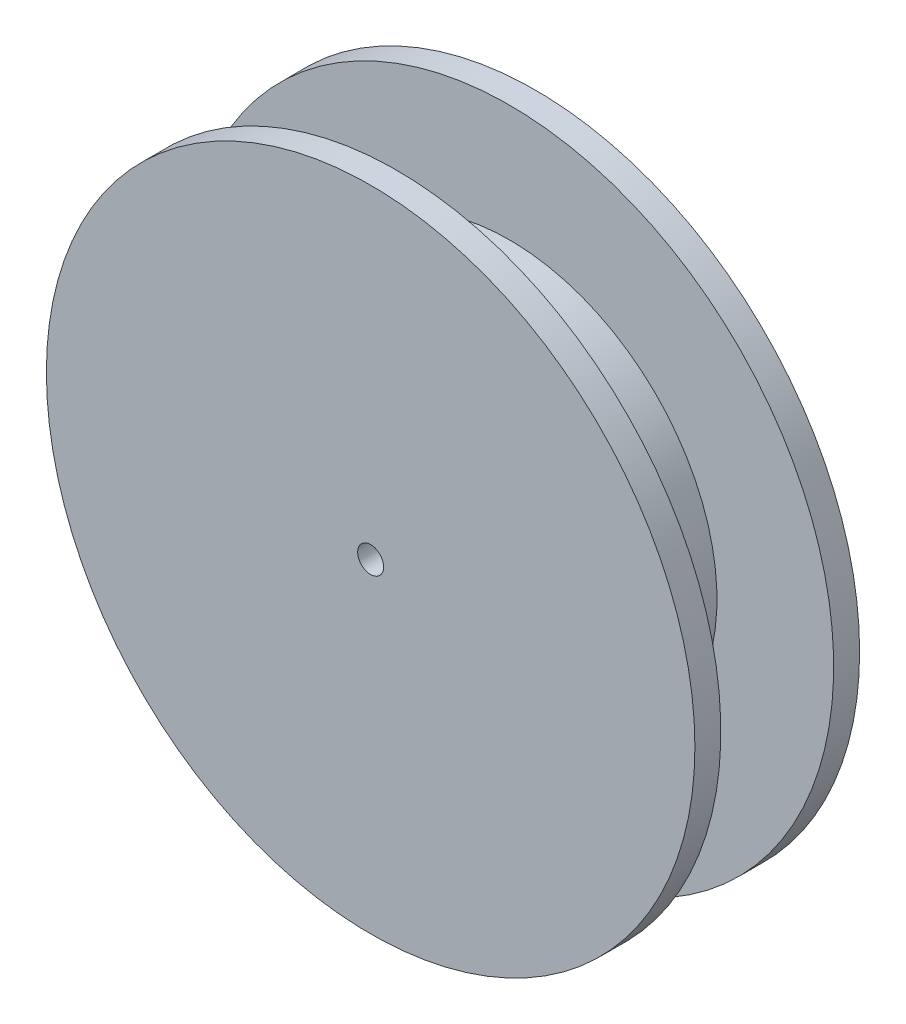
from build123d import *

# Parameters (mm, degrees)
SKETCH1_R           = 12.5
SKETCH1_R_2         = 0.5
BOSS_EXTRUDE1_DEPTH = 6.35
SKETCH2_W           = 4.35
SKETCH2_H           = 4.5


with BuildPart() as part:
    # Sketch1 → Boss-Extrude1 (new body)
    with BuildSketch(Plane.XY):
        Circle(SKETCH1_R)
        Circle(SKETCH1_R_2, mode=Mode.SUBTRACT)
    extrude(amount=BOSS_EXTRUDE1_DEPTH)

    # Sketch2 → Cut-Revolve1 (revolve, cut)
    with BuildSketch(Plane(origin=(0, 0, 0), x_dir=(0, 0, -1), z_dir=(1, 0, 0))):
        with Locations((-3.175, 10.25)):
            Rectangle(SKETCH2_W, SKETCH2_H)
    revolve(axis=Axis((0, 0, 0), (0, 0, 1)), mode=Mode.SUBTRACT)


solid = part.part
